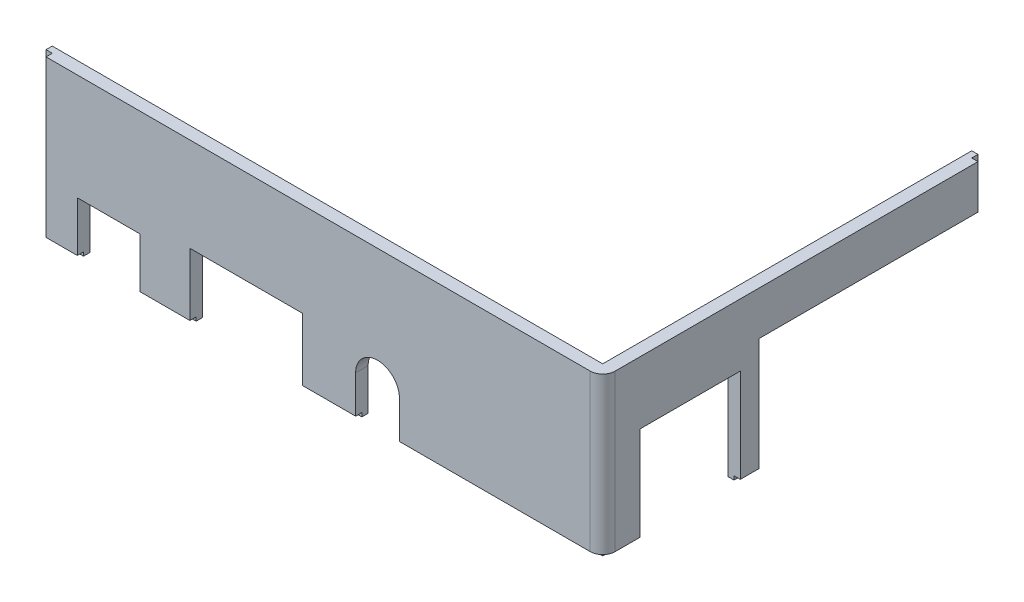
from build123d import *

# Parameters (mm, degrees)
P_IDAT_VYSUNUT_M1_DEPTH  = 25
SKICA2_W                 = 88
SKICA2_H                 = 1
P_IDAT_VYSUNUT_M2_DEPTH  = 0.6
ODEBRAT_VYSUNUT_M1_REACH = 63
SKICA5_W                 = 10
SKICA5_H                 = 8.6
SKICA5_W_2               = 18
SKICA5_H_2               = 10.6
ODEBRAT_VYSUNUT_M2_REACH = 92
SKICA6_W                 = 16
SKICA6_H                 = 15.6
SKICA6_W_2               = 19
SKICA6_H_2               = 18.6
FILLET1_R                = 2
CUT_EXTRUDE2_REACH       = 92
SKETCH2_W                = 1
SKETCH2_H                = 18.6


with BuildPart() as part:
    # Skica1 → Přidat vysunutím1 (new body)
    with BuildSketch(Plane(origin=(0, 0, 0), x_dir=(1, 0, 0), z_dir=(0, 1, 0))):
        Polygon((88, 2), (90, 2), (90, 60), (89, 60), (89, 61), (88, 61), align=None)
        Polygon((1, 1), (1, 0), (90, 0), (90, 2), (88, 2), (0, 2), (0, 1), align=None)
    extrude(amount=P_IDAT_VYSUNUT_M1_DEPTH)

    # Skica2 → Přidat vysunutím2 (add)
    with BuildSketch(Plane.XZ):
        with Locations((44, -1.5)):
            Rectangle(SKICA2_W, SKICA2_H)
        Polygon((89, -1), (88, -1), (88, -2), (88, -61), (89, -61), align=None)
    extrude(amount=P_IDAT_VYSUNUT_M2_DEPTH)

    # Skica5 → Odebrat vysunutím1 (cut, up to next)
    with BuildSketch(Plane.XY, mode=Mode.PRIVATE) as odebrat_vysunut_m1_sk1:
        with Locations((11, 3.7)):
            Rectangle(SKICA5_W, SKICA5_H)
    odebrat_vysunut_m1_tool1 = extrude(odebrat_vysunut_m1_sk1.sketch, amount=-ODEBRAT_VYSUNUT_M1_REACH, mode=Mode.PRIVATE) & part.part
    add(odebrat_vysunut_m1_tool1.solids().sort_by_distance((11, 3.7, 0))[0], mode=Mode.SUBTRACT)
    # Skica5 → Odebrat vysunutím1 (cut, up to next)
    with BuildSketch(Plane.XY, mode=Mode.PRIVATE) as odebrat_vysunut_m1_sk2:
        with Locations((33, 4.7)):
            Rectangle(SKICA5_W_2, SKICA5_H_2)
    odebrat_vysunut_m1_tool2 = extrude(odebrat_vysunut_m1_sk2.sketch, amount=-ODEBRAT_VYSUNUT_M1_REACH, mode=Mode.PRIVATE) & part.part
    add(odebrat_vysunut_m1_tool2.solids().sort_by_distance((33, 4.7, 0))[0], mode=Mode.SUBTRACT)
    # Skica5 → Odebrat vysunutím1 (cut, up to next)
    with BuildSketch(Plane.XY, mode=Mode.PRIVATE) as odebrat_vysunut_m1_sk3:
        with BuildLine():
            Line((50.5, 6), (50.5, -0.6))
            Line((50.5, -0.6), (57.5, -0.6))
            Line((57.5, -0.6), (57.5, 6))
            ThreePointArc((57.5, 6), (54, 9.5), (50.5, 6))
        make_face()
    odebrat_vysunut_m1_tool3 = extrude(odebrat_vysunut_m1_sk3.sketch, amount=-ODEBRAT_VYSUNUT_M1_REACH, mode=Mode.PRIVATE) & part.part
    add(odebrat_vysunut_m1_tool3.solids().sort_by_distance((54, 4.107084, 0))[0], mode=Mode.SUBTRACT)

    # Skica6 → Odebrat vysunutím2 (cut, up to next)
    with BuildSketch(Plane(origin=(90, 0, 0), x_dir=(0, 0, -1), z_dir=(1, 0, 0)), mode=Mode.PRIVATE) as odebrat_vysunut_m2_sk1:
        with Locations((14, 7.2)):
            Rectangle(SKICA6_W, SKICA6_H)
    odebrat_vysunut_m2_tool1 = extrude(odebrat_vysunut_m2_sk1.sketch, amount=-ODEBRAT_VYSUNUT_M2_REACH, mode=Mode.PRIVATE) & part.part
    add(odebrat_vysunut_m2_tool1.solids().sort_by_distance((90, 7.2, -14))[0], mode=Mode.SUBTRACT)
    # Skica6 → Odebrat vysunutím2 (cut, up to next)
    with BuildSketch(Plane(origin=(90, 0, 0), x_dir=(0, 0, -1), z_dir=(1, 0, 0)), mode=Mode.PRIVATE) as odebrat_vysunut_m2_sk2:
        with Locations((51.5, 8.7)):
            Rectangle(SKICA6_W_2, SKICA6_H_2)
    odebrat_vysunut_m2_tool2 = extrude(odebrat_vysunut_m2_sk2.sketch, amount=-ODEBRAT_VYSUNUT_M2_REACH, mode=Mode.PRIVATE) & part.part
    add(odebrat_vysunut_m2_tool2.solids().sort_by_distance((90, 8.7, -51.5))[0], mode=Mode.SUBTRACT)
    # Skica6 → Odebrat vysunutím2 (cut, up to next)
    with BuildSketch(Plane(origin=(90, 0, 0), x_dir=(0, 0, -1), z_dir=(1, 0, 0)), mode=Mode.PRIVATE) as odebrat_vysunut_m2_sk3:
        with Locations((33, 8.7)):
            Rectangle(SKICA6_W, SKICA6_H_2)
    odebrat_vysunut_m2_tool3 = extrude(odebrat_vysunut_m2_sk3.sketch, amount=-ODEBRAT_VYSUNUT_M2_REACH, mode=Mode.PRIVATE) & part.part
    add(odebrat_vysunut_m2_tool3.solids().sort_by_distance((90, 8.7, -33))[0], mode=Mode.SUBTRACT)

    # Fillet1
    fillet1_edges = [part.edges().sort_by_distance(p)[0] for p in [
        (90, 12.5, 0),
    ]]
    fillet(fillet1_edges, radius=FILLET1_R)

    # Sketch2 → Cut-Extrude2 (cut, up to next)
    with BuildSketch(Plane(origin=(90, 0, 0), x_dir=(0, 0, -1), z_dir=(1, 0, 0)), mode=Mode.PRIVATE) as cut_extrude2_sk1:
        with Locations((41.5, 8.7)):
            Rectangle(SKETCH2_W, SKETCH2_H)
    cut_extrude2_tool1 = extrude(cut_extrude2_sk1.sketch, amount=-CUT_EXTRUDE2_REACH, mode=Mode.PRIVATE) & part.part
    add(cut_extrude2_tool1.solids().sort_by_distance((90, 8.7, -41.5))[0], mode=Mode.SUBTRACT)


solid = part.part
